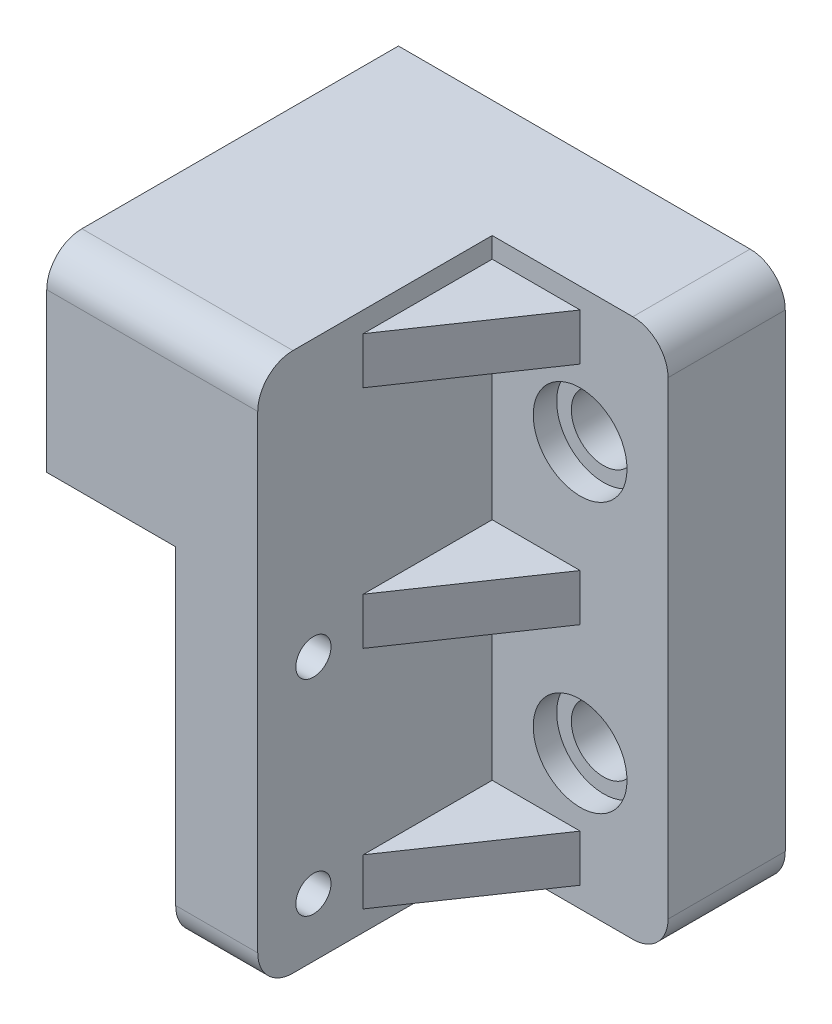
from build123d import *

# Parameters (mm, degrees)
ESBO_O1_W                = 7
ESBO_O1_H                = 30
RESSALTO_EXTRUS_O1_DEPTH = 46
RESSALTO_EXTRUS_O2_DEPTH = 11
FILETE1_R                = 3
ESBO_O3_R                = 1.5
CORTE_EXTRUS_O1_DEPTH    = 8
ESBO_O4_W                = 10
ESBO_O4_H                = 46
RESSALTO_EXTRUS_O4_DEPTH = 15
ESBO_O5_R                = 2.75
CORTE_EXTRUS_O2_DEPTH    = 11
ESBO_O6_R                = 4
CORTE_EXTRUS_O3_DEPTH    = 2
ESBO_O7_W                = 7.5
ESBO_O7_H                = 4
RESSALTO_EXTRUS_O5_DEPTH = 11
CORTE_EXTRUS_O4_DEPTH    = 45.25
FILETE2_R                = 3
FILETE3_R                = 3
ESBO_O9_R                = 2
CORTE_EXTRUS_O5_DEPTH    = 22
ESBO_O15_R               = 1.5
CORTE_EXTRUS_O6_DEPTH    = 22
CORTE_EXTRUS_O7_DEPTH    = 2.5


with BuildPart() as part:
    # Esboço1 → Ressalto-extrusão1 (new body)
    with BuildSketch(Plane(origin=(0, 0, 0), x_dir=(1, 0, 0), z_dir=(0, 1, 0))):
        Rectangle(ESBO_O1_W, ESBO_O1_H)
    extrude(amount=RESSALTO_EXTRUS_O1_DEPTH)

    # Esboço2 → Ressalto-extrusão2 (add)
    with BuildSketch(Plane.ZY.offset(3.5)):
        Polygon((0, 40), (-7.5, 40), (-7.5, 29.5), (-15, 29.5), (-15, 46), (15, 46), (15, 29.5), (7.5, 29.5), (7.5, 40), align=None)
    extrude(amount=RESSALTO_EXTRUS_O2_DEPTH)

    # Filete1
    filete1_edges = [part.edges().sort_by_distance(p)[0] for p in [
        (-14.5, 34.75, -7.5),
        (-14.5, 34.75, 7.5),
    ]]
    fillet(filete1_edges, radius=FILETE1_R)

    # Esboço3 → Corte-extrusão1 (cut, through all)
    with BuildSketch(Plane.ZY.offset(3.5)):
        with Locations((-10.25, 5)):
            Circle(ESBO_O3_R)
        with Locations((10.25, 5)):
            Circle(ESBO_O3_R)
        with Locations((-10.25, 22.5)):
            Circle(ESBO_O3_R)
        with Locations((10.25, 22.5)):
            Circle(ESBO_O3_R)
    extrude(amount=-CORTE_EXTRUS_O1_DEPTH, mode=Mode.SUBTRACT)

    # Esboço4 → Ressalto-extrusão4 (add)
    with BuildSketch(Plane(origin=(3.5, 0, 0), x_dir=(0, 0, -1), z_dir=(1, 0, 0))):
        with Locations((10, 23)):
            Rectangle(ESBO_O4_W, ESBO_O4_H)
    extrude(amount=RESSALTO_EXTRUS_O4_DEPTH)

    # Esboço5 → Corte-extrusão2 (cut, through all)
    with BuildSketch(Plane.XY.offset(-5)):
        with Locations((11, 11.5)):
            Circle(ESBO_O5_R)
        with Locations((11, 34.5)):
            Circle(ESBO_O5_R)
    extrude(amount=-CORTE_EXTRUS_O2_DEPTH, mode=Mode.SUBTRACT)

    # Esboço6 → Corte-extrusão3 (cut)
    with BuildSketch(Plane.XY.offset(-5)):
        with Locations((11, 11.5)):
            Circle(ESBO_O6_R)
        with Locations((11, 34.5)):
            Circle(ESBO_O6_R)
    extrude(amount=-CORTE_EXTRUS_O3_DEPTH, mode=Mode.SUBTRACT)

    # Esboço7 → Ressalto-extrusão5 (add)
    with BuildSketch(Plane.XY.offset(-5)):
        with Locations((7.25, 3.75)):
            Rectangle(ESBO_O7_W, ESBO_O7_H)
        with Locations((7.25, 23)):
            Rectangle(ESBO_O7_W, ESBO_O7_H)
        with Locations((7.25, 42.25)):
            Rectangle(ESBO_O7_W, ESBO_O7_H)
    extrude(amount=RESSALTO_EXTRUS_O5_DEPTH)

    # Esboço8 → Corte-extrusão4 (cut, through all)
    with BuildSketch(Plane.XZ.offset(-1.75)):
        Polygon((11, -5), (3.5, 6), (11, 6), align=None)
    extrude(amount=-CORTE_EXTRUS_O4_DEPTH, mode=Mode.SUBTRACT)

    # Filete2
    filete2_edges = [part.edges().sort_by_distance(p)[0] for p in [
        (-5.5, 46, 15),
        (0, 0, 15),
    ]]
    fillet(filete2_edges, radius=FILETE2_R)

    # Filete3
    filete3_edges = [part.edges().sort_by_distance(p)[0] for p in [
        (18.5, 46, -10),
        (18.5, 0, -10),
    ]]
    fillet(filete3_edges, radius=FILETE3_R)

    # Esboço9 → Corte-extrusão5 (cut)
    with BuildSketch(Plane(origin=(0, 0, -15), x_dir=(-1, 0, 0), z_dir=(0, 0, -1))):
        with Locations((11.5, 43)):
            Circle(ESBO_O9_R)
    extrude(amount=-CORTE_EXTRUS_O5_DEPTH, mode=Mode.SUBTRACT)

    # Esboço15 → Corte-extrusão6 (cut)
    with BuildSketch(Plane(origin=(-14.75, 0, -14.75), x_dir=(0, -1, 0), z_dir=(-0.707106781, 0, -0.707106781))):
        with Locations((-38, -6.01040764)):
            Circle(ESBO_O15_R)
    extrude(amount=-CORTE_EXTRUS_O6_DEPTH, mode=Mode.SUBTRACT)

    # Esboço16 → Corte-extrusão7 (cut)
    with BuildSketch(Plane(origin=(0, 0, -15), x_dir=(-1, 0, 0), z_dir=(0, 0, -1))):
        Polygon((6.5, 39.5), (9.5, 43), (11.5, 41), (8.621320344, 38), align=None)
    extrude(amount=-CORTE_EXTRUS_O7_DEPTH, mode=Mode.SUBTRACT)


solid = part.part
